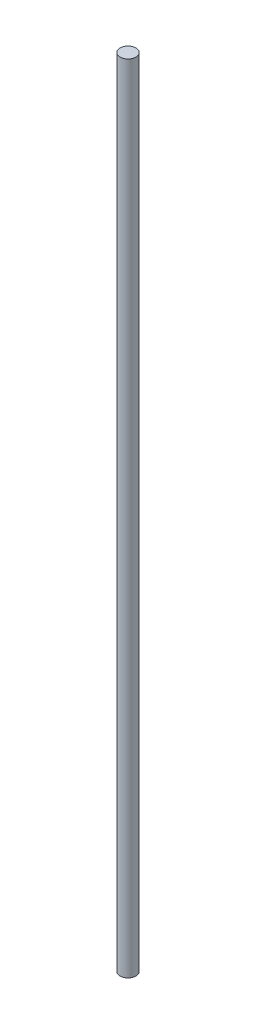
from build123d import *

# Parameters (mm, degrees)
SKETCH_1_R      = 3
EXTRUDE_1_DEPTH = 300.5


with BuildPart() as part:
    # Эскиз1 → Бобышка-Вытянуть1 (new body)
    with BuildSketch(Plane(origin=(0, 0, 0), x_dir=(1, 0, 0), z_dir=(0, 1, 0))):
        Circle(SKETCH_1_R)
    extrude(amount=EXTRUDE_1_DEPTH)


solid = part.part
